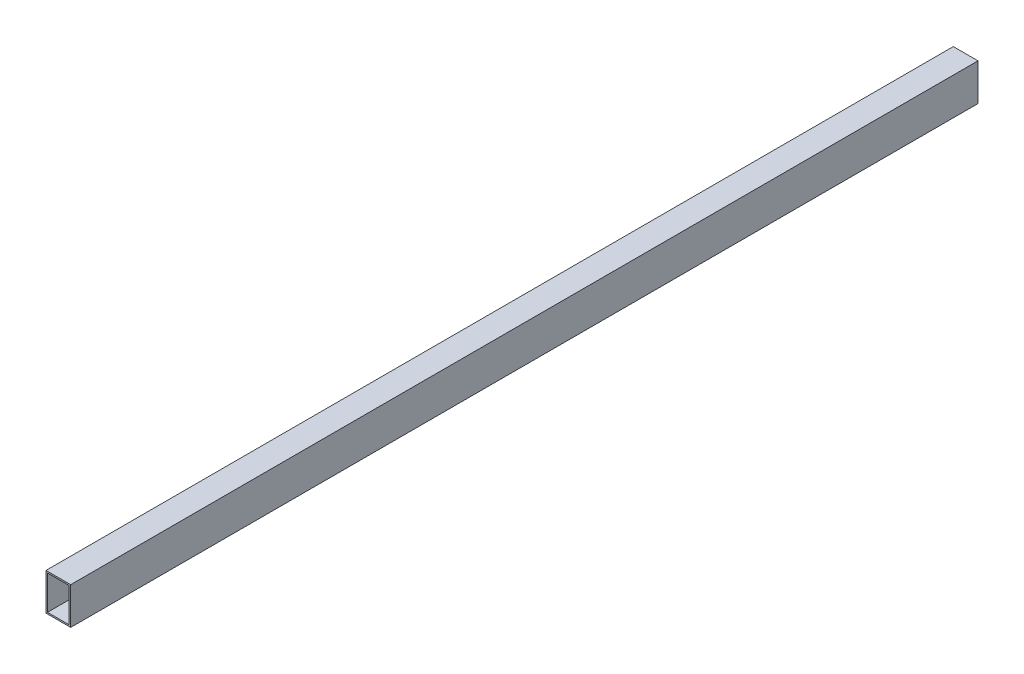
from build123d import *

# Parameters (mm, degrees)
SKETCH1_W           = 100
SKETCH1_H           = 150
SKETCH1_W_2         = 88
SKETCH1_H_2         = 138
BOSS_EXTRUDE2_DEPTH = 3675


with BuildPart() as part:
    # Sketch1 → Boss-Extrude2 (new body)
    with BuildSketch(Plane.XY):
        Rectangle(SKETCH1_W, SKETCH1_H)
        Rectangle(SKETCH1_W_2, SKETCH1_H_2, mode=Mode.SUBTRACT)
    extrude(amount=BOSS_EXTRUDE2_DEPTH)


solid = part.part
